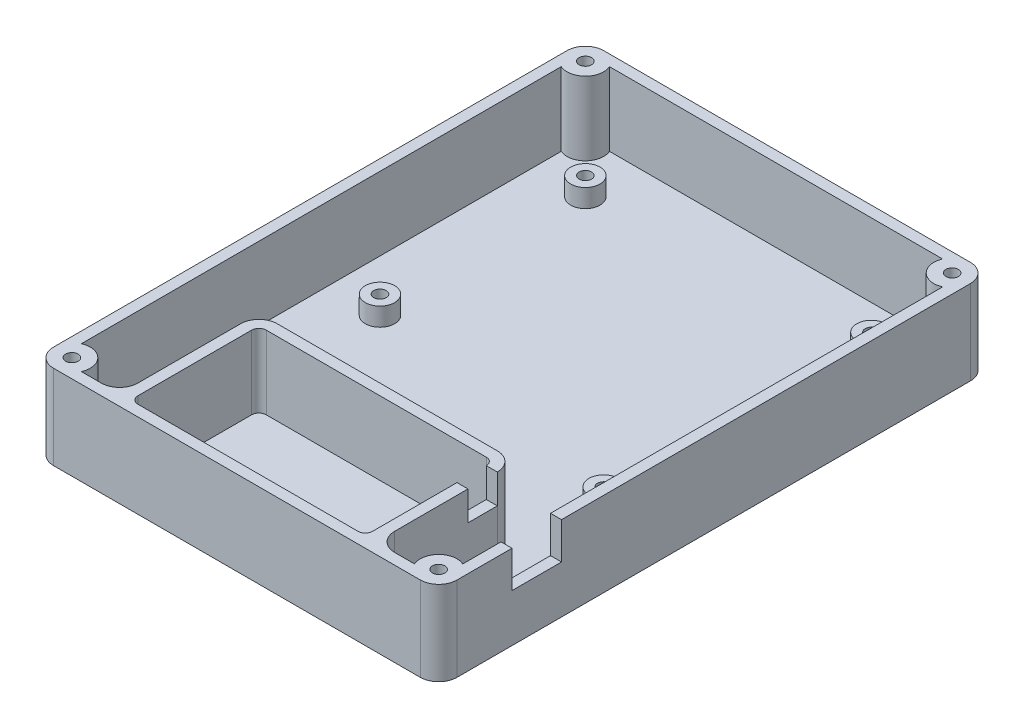
from build123d import *

# Parameters (mm, degrees)
ESBO_O1_W                                            = 110
ESBO_O1_H                                            = 150
RESSALTO_EXTRUS_O3_DEPTH                             = 23
FILETE2_R                                            = 5
CASCA1_T                                             = -3
ESBO_O14_R                                           = 5
RESSALTO_EXTRUS_O7_DEPTH                             = 20
RESSALTO_EXTRUS_O4_DEPTH                             = 23
FILETE6_R                                            = 2
FILETE8_R                                            = 5
ESBO_O7_W                                            = 3
ESBO_O7_H                                            = 8
CORTE_EXTRUS_O1_DEPTH                                = 8
ESBO_O8_W                                            = 3
ESBO_O8_H                                            = 13.5
CORTE_EXTRUS_O2_DEPTH                                = 10
ESBO_O17_R                                           = 4
RESSALTO_EXTRUS_O8_DEPTH                             = 5
ESCAREADO_PARA_PARAFUSO_DE_M_QUINA_COM_C_D           = 3.4
ESCAREADO_PARA_PARAFUSO_DE_M_QUINA_COM_C_DEPTH       = 15
ESCAREADO_PARA_PARAFUSO_DE_M_QUINA_COM_C_CSINK_D     = 6.3
ESCAREADO_PARA_PARAFUSO_DE_M_QUINA_COM_C_CSINK_ANGLE = 90
ESCAREADO_PARA_PARAFUSO_DE_M_QUINA_COM_C_TIP         = 1.021463052
ESCAREADO_PARA_PARAFUSO_DE_M_QUINA_C_2_D             = 3.4
ESCAREADO_PARA_PARAFUSO_DE_M_QUINA_C_2_CSINK_D       = 6.3
ESCAREADO_PARA_PARAFUSO_DE_M_QUINA_C_2_CSINK_ANGLE   = 90


with BuildPart() as part:
    # Esboço1 → Ressalto-extrusão3 (new body)
    with BuildSketch(Plane(origin=(0, 0, 0), x_dir=(1, 0, 0), z_dir=(0, 1, 0))):
        Rectangle(ESBO_O1_W, ESBO_O1_H)
    extrude(amount=RESSALTO_EXTRUS_O3_DEPTH)

    # Filete2
    filete2_edges = [part.edges().sort_by_distance(p)[0] for p in [
        (55, 11.5, 75),
        (-55, 11.5, 75),
        (-55, 11.5, -75),
        (55, 11.5, -75),
    ]]
    fillet(filete2_edges, radius=FILETE2_R)

    # Casca1
    casca1_openings = [part.faces().sort_by_distance(p)[0] for p in [
        (0, 23, 0),
    ]]
    offset(amount=CASCA1_T, openings=casca1_openings, kind=Kind.INTERSECTION)

    # Esboço14 → Ressalto-extrusão7 (add)
    with BuildSketch(Plane(origin=(0, 3, 0), x_dir=(1, 0, 0), z_dir=(0, 1, 0))):
        with Locations((-50, -70)):
            Circle(ESBO_O14_R)
        with Locations((50, -70)):
            Circle(ESBO_O14_R)
        with Locations((50, 70)):
            Circle(ESBO_O14_R)
        with Locations((-50, 70)):
            Circle(ESBO_O14_R)
    extrude(amount=RESSALTO_EXTRUS_O7_DEPTH)

    # Esboço6 → Ressalto-extrusão4 (add)
    with BuildSketch(Plane(origin=(0, 0, 0), x_dir=(1, 0, 0), z_dir=(0, 1, 0))):
        Polygon((-32, -37), (32, -37), (32, -72), (35, -72), (35, -34), (-35, -34), (-35, -72), (-32, -72), align=None)
    extrude(amount=RESSALTO_EXTRUS_O4_DEPTH)

    # Filete6
    filete6_edges = [part.edges().sort_by_distance(p)[0] for p in [
        (32, 13, 37),
        (-32, 13, 37),
        (-32, 13, 72),
        (32, 13, 72),
    ]]
    fillet(filete6_edges, radius=FILETE6_R)

    # Filete8
    filete8_edges = [part.edges().sort_by_distance(p)[0] for p in [
        (-35, 13, 72),
        (-35, 13, 34),
        (35, 13, 34),
        (35, 13, 72),
    ]]
    fillet(filete8_edges, radius=FILETE8_R)

    # Esboço7 → Corte-extrusão1 (cut)
    with BuildSketch(Plane(origin=(0, 23, 0), x_dir=(1, 0, 0), z_dir=(0, 1, 0))):
        with Locations((33.5, -43)):
            Rectangle(ESBO_O7_W, ESBO_O7_H)
    extrude(amount=-CORTE_EXTRUS_O1_DEPTH, mode=Mode.SUBTRACT)

    # Esboço8 → Corte-extrusão2 (cut)
    with BuildSketch(Plane(origin=(0, 23, 0), x_dir=(1, 0, 0), z_dir=(0, 1, 0))):
        with Locations((53.5, -48.25)):
            Rectangle(ESBO_O8_W, ESBO_O8_H)
    extrude(amount=-CORTE_EXTRUS_O2_DEPTH, mode=Mode.SUBTRACT)

    # Esboço17 → Ressalto-extrusão8 (add)
    with BuildSketch(Plane(origin=(0, 3, 0), x_dir=(1, 0, 0), z_dir=(0, 1, 0))):
        with Locations((-38, 58)):
            Circle(ESBO_O17_R)
        with Locations((-38, 2)):
            Circle(ESBO_O17_R)
        with Locations((38, -13)):
            Circle(ESBO_O17_R)
        with Locations((38, 60)):
            Circle(ESBO_O17_R)
    extrude(amount=RESSALTO_EXTRUS_O8_DEPTH)

    # Escareado para parafuso de m_quina com c
    with Locations(Plane(origin=(0, 0, 0), x_dir=(-1, 0, 0), z_dir=(0, -1, 0))):
        with Locations((-38, -13), (38, 2), (38, 58), (-38, 60)):
            CounterSinkHole(ESCAREADO_PARA_PARAFUSO_DE_M_QUINA_COM_C_D / 2, ESCAREADO_PARA_PARAFUSO_DE_M_QUINA_COM_C_CSINK_D / 2, depth=ESCAREADO_PARA_PARAFUSO_DE_M_QUINA_COM_C_DEPTH, counter_sink_angle=ESCAREADO_PARA_PARAFUSO_DE_M_QUINA_COM_C_CSINK_ANGLE)
            with Locations((0, 0, -(ESCAREADO_PARA_PARAFUSO_DE_M_QUINA_COM_C_DEPTH + ESCAREADO_PARA_PARAFUSO_DE_M_QUINA_COM_C_TIP / 2))):  # 118° drill point
                Cone(0, ESCAREADO_PARA_PARAFUSO_DE_M_QUINA_COM_C_D / 2, ESCAREADO_PARA_PARAFUSO_DE_M_QUINA_COM_C_TIP, mode=Mode.SUBTRACT)

    # Escareado para parafuso de m_quina c 2 (through all)
    with Locations(Plane(origin=(0, 0, 0), x_dir=(-1, 0, 0), z_dir=(0, -1, 0))):
        with Locations((50, -70), (-50, -70), (-50, 70), (50, 70)):
            CounterSinkHole(ESCAREADO_PARA_PARAFUSO_DE_M_QUINA_C_2_D / 2, ESCAREADO_PARA_PARAFUSO_DE_M_QUINA_C_2_CSINK_D / 2, counter_sink_angle=ESCAREADO_PARA_PARAFUSO_DE_M_QUINA_C_2_CSINK_ANGLE)


solid = part.part
